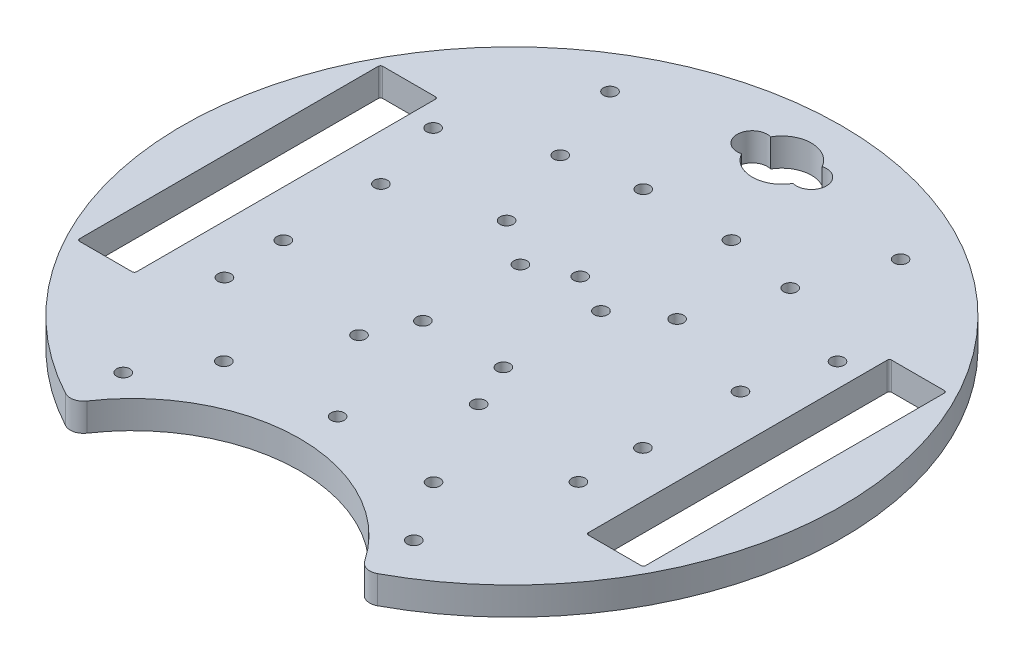
from build123d import *

# Parameters (mm, degrees)
SKETCH1_R           = 1.5
BOSS_EXTRUDE2_DEPTH = 6.35


with BuildPart() as part:
    # Sketch1 → Boss-Extrude2 (new body)
    with BuildSketch(Plane(origin=(0, 0, 0), x_dir=(1, 0, 0), z_dir=(0, 1, 0))):
        with BuildLine():
            ThreePointArc((35.49727084, -66.067721036), (0, 75), (-35.49727084, -66.067721036))
            ThreePointArc((-35.49727084, -66.067721036), (-33.357679643, -66.33740492), (-31.589980006, -65.102164912))
            ThreePointArc((-31.589980006, -65.102164912), (0, -48.302004425), (31.589980006, -65.102164912))
            ThreePointArc((31.589980006, -65.102164912), (33.357679643, -66.33740492), (35.49727084, -66.067721036))
        make_face()
        with Locations((-13.608916499, -21.183093811)):
            Circle(SKETCH1_R, mode=Mode.SUBTRACT)
        with Locations((-46.011477091, 28.075890486)):
            Circle(SKETCH1_R, mode=Mode.SUBTRACT)
        with Locations((13.608916499, -21.183093811)):
            Circle(SKETCH1_R, mode=Mode.SUBTRACT)
        with Locations((23.852486199, -41.694616163)):
            Circle(SKETCH1_R, mode=Mode.SUBTRACT)
        with Locations((-40.910067426, 11.1)):
            Circle(SKETCH1_R, mode=Mode.SUBTRACT)
        with Locations((-40.910067426, -11.1)):
            Circle(SKETCH1_R, mode=Mode.SUBTRACT)
        with Locations((-9.160067426, -11.1)):
            Circle(SKETCH1_R, mode=Mode.SUBTRACT)
        with Locations((-9.160067426, 11.1)):
            Circle(SKETCH1_R, mode=Mode.SUBTRACT)
        with Locations((9.160067426, 11.1)):
            Circle(SKETCH1_R, mode=Mode.SUBTRACT)
        with Locations((9.160067426, -11.1)):
            Circle(SKETCH1_R, mode=Mode.SUBTRACT)
        with Locations((40.910067426, -11.1)):
            Circle(SKETCH1_R, mode=Mode.SUBTRACT)
        with Locations((40.910067426, 11.1)):
            Circle(SKETCH1_R, mode=Mode.SUBTRACT)
        with Locations((-23.852486199, -41.694616163)):
            Circle(SKETCH1_R, mode=Mode.SUBTRACT)
        with Locations((19.397913834, 18.186588214)):
            Circle(SKETCH1_R, mode=Mode.SUBTRACT)
        with Locations((-40.277379234, -25.14022965)):
            Circle(SKETCH1_R, mode=Mode.SUBTRACT)
        with Locations((40.277379234, -25.14022965)):
            Circle(SKETCH1_R, mode=Mode.SUBTRACT)
        with Locations((26.163250867, 37.1696126)):
            Circle(SKETCH1_R, mode=Mode.SUBTRACT)
        with Locations((46.011477091, 28.075890486)):
            Circle(SKETCH1_R, mode=Mode.SUBTRACT)
        with Locations((10.027203595, 39.91869143)):
            Circle(SKETCH1_R, mode=Mode.SUBTRACT)
        with Locations((0, -39.659190322)):
            Circle(SKETCH1_R, mode=Mode.SUBTRACT)
        with Locations((-10.027203595, 39.91869143)):
            Circle(SKETCH1_R, mode=Mode.SUBTRACT)
        with Locations((-33.059737365, -55.383244446)):
            Circle(SKETCH1_R, mode=Mode.SUBTRACT)
        with Locations((-33.059737365, 55.383244446)):
            Circle(SKETCH1_R, mode=Mode.SUBTRACT)
        with Locations((33.059737365, -55.383244446)):
            Circle(SKETCH1_R, mode=Mode.SUBTRACT)
        with Locations((0, 15.543589551)):
            Circle(SKETCH1_R, mode=Mode.SUBTRACT)
        with Locations((-26.163250867, 37.1696126)):
            Circle(SKETCH1_R, mode=Mode.SUBTRACT)
        with Locations((-19.397913834, 18.186588214)):
            Circle(SKETCH1_R, mode=Mode.SUBTRACT)
        with Locations((33.059737365, 55.383244446)):
            Circle(SKETCH1_R, mode=Mode.SUBTRACT)
        with BuildLine():
            Line((51.410067426, -34), (51.410067426, 34))
            ThreePointArc((51.410067426, 34), (51.556514035, 34.353553391), (51.910067426, 34.5))
            Line((51.910067426, 34.5), (63.910067426, 34.5))
            ThreePointArc((63.910067426, 34.5), (64.263620817, 34.353553391), (64.410067426, 34))
            Line((64.410067426, 34), (64.410067426, -34))
            ThreePointArc((64.410067426, -34), (64.263620817, -34.353553391), (63.910067426, -34.5))
            Line((63.910067426, -34.5), (51.910067426, -34.5))
            ThreePointArc((51.910067426, -34.5), (51.556514035, -34.353553391), (51.410067426, -34))
        make_face(mode=Mode.SUBTRACT)
        with BuildLine():
            Line((-63.910067426, -34.5), (-51.910067426, -34.5))
            ThreePointArc((-51.910067426, -34.5), (-51.556514035, -34.353553391), (-51.410067426, -34))
            Line((-51.410067426, -34), (-51.410067426, 34))
            ThreePointArc((-51.410067426, 34), (-51.556514035, 34.353553391), (-51.910067426, 34.5))
            Line((-51.910067426, 34.5), (-63.910067426, 34.5))
            ThreePointArc((-63.910067426, 34.5), (-64.263620817, 34.353553391), (-64.410067426, 34))
            Line((-64.410067426, 34), (-64.410067426, -34))
            ThreePointArc((-64.410067426, -34), (-64.263620817, -34.353553391), (-63.910067426, -34.5))
        make_face(mode=Mode.SUBTRACT)
        with BuildLine():
            ThreePointArc((-5.853899988, 64.744946271), (0.003726822, 68.153564176), (5.857575472, 64.738461857))
            ThreePointArc((5.857575472, 64.738461857), (10.16, 61.422565207), (5.857575472, 58.106668557))
            ThreePointArc((5.857575472, 58.106668557), (0.003726822, 54.691566239), (-5.853899988, 58.100184144))
            ThreePointArc((-5.853899988, 58.100184144), (-10.167207264, 61.422565207), (-5.853899988, 64.744946271))
        make_face(mode=Mode.SUBTRACT)
    extrude(amount=BOSS_EXTRUDE2_DEPTH)


solid = part.part
